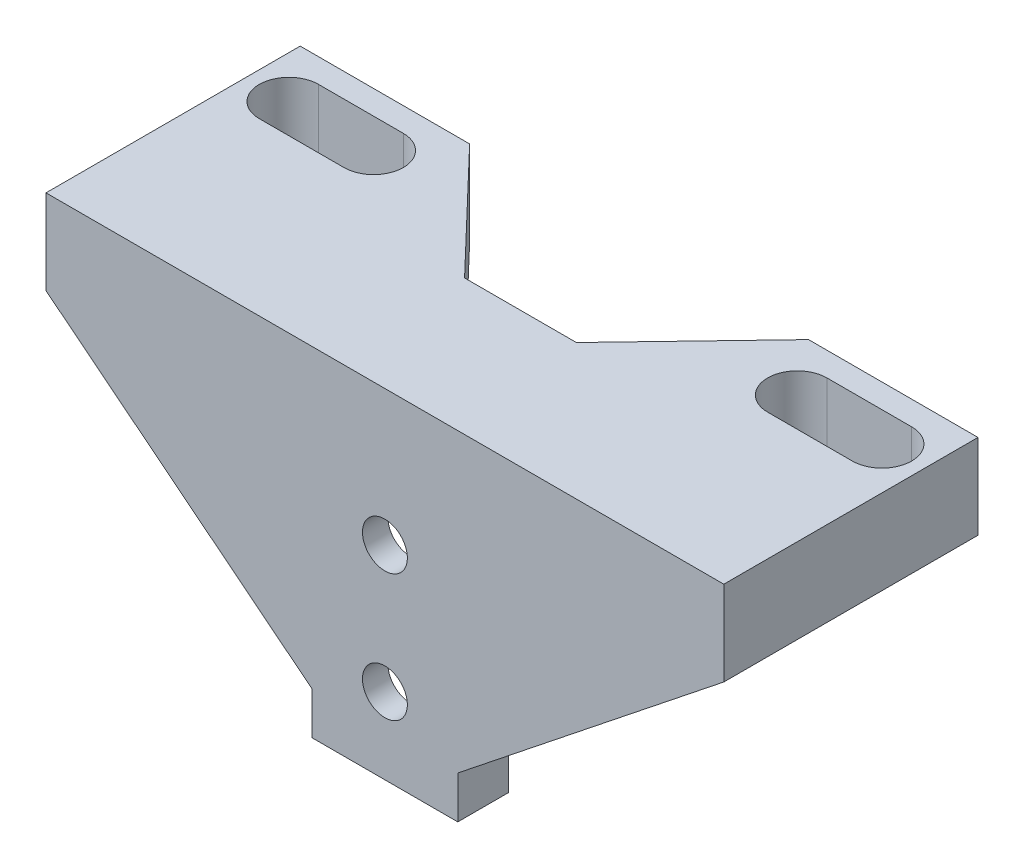
from build123d import *

# Parameters (mm, degrees)
ESQUISSE1_W             = 13.2
ESQUISSE1_H             = 30
ESQUISSE1_W_2           = 2
BOSS_EXTRU_1_DEPTH      = 3
ESQUISSE2_W             = 2
ESQUISSE2_H             = 30
BOSS_EXTRU_2_DEPTH      = 3
BOSS_EXTRU_3_DEPTH      = 10
BOSS_EXTRU_4_DEPTH      = 6
ESQUISSE6_R             = 2.65
ENL_V_MAT_EXTRU_1_DEPTH = 4
ENL_V_MAT_EXTRU_2_DEPTH = 41
CHANFREIN2_SIZE         = 10


with BuildPart() as part:
    # Esquisse1 → Boss.-Extru.1 (new body)
    with BuildSketch(Plane.XY):
        with Locations((-0.437888948, -2.316831683)):
            Rectangle(ESQUISSE1_W, ESQUISSE1_H)
        with Locations((-8.037888948, -2.316831683)):
            Rectangle(ESQUISSE1_W_2, ESQUISSE1_H)
        with Locations((7.162111052, -2.316831683)):
            Rectangle(ESQUISSE1_W_2, ESQUISSE1_H)
    extrude(amount=BOSS_EXTRU_1_DEPTH)

    # Esquisse2 → Boss.-Extru.2 (add)
    with BuildSketch(Plane(origin=(0, 0, 0), x_dir=(-1, 0, 0), z_dir=(0, 0, -1))):
        with Locations((-7.162111052, -2.316831683)):
            Rectangle(ESQUISSE2_W, ESQUISSE2_H)
        with Locations((8.037888948, -2.316831683)):
            Rectangle(ESQUISSE2_W, ESQUISSE2_H)
    extrude(amount=BOSS_EXTRU_2_DEPTH)

    # Esquisse3 → Boss.-Extru.3 (add)
    with BuildSketch(Plane(origin=(0, 12.683168317, 0), x_dir=(1, 0, 0), z_dir=(0, 1, 0))):
        Polygon((19.562111052, 27), (6.162111052, 13), (-7.037888948, 13), (-20.437888948, 27), (-40.437888948, 27), (-40.437888948, -3), (39.562111052, -3), (39.562111052, 27), align=None)
    extrude(amount=BOSS_EXTRU_3_DEPTH)

    # Esquisse5 → Boss.-Extru.4 (add)
    with BuildSketch(Plane.XY.offset(3)):
        Polygon((-9.037888948, 12.683168317), (-40.437888948, 12.683168317), (-9.037888948, -12.316831683), align=None)
        Polygon((8.162111052, -12.316831683), (39.562111052, 12.683168317), (8.162111052, 12.683168317), align=None)
    extrude(amount=-BOSS_EXTRU_4_DEPTH)

    # Esquisse6 → Enlèv. mat.-Extru.1 (cut, through all)
    with BuildSketch(Plane(origin=(0, 0, 0), x_dir=(-1, 0, 0), z_dir=(0, 0, -1))):
        with Locations((0.437888948, 6.683168317)):
            Circle(ESQUISSE6_R)
        with Locations((0.437888948, -8.316831683)):
            Circle(ESQUISSE6_R)
    extrude(amount=-ENL_V_MAT_EXTRU_1_DEPTH, mode=Mode.SUBTRACT)

    # Esquisse7 → Enlèv. mat.-Extru.2 (cut, through all)
    with BuildSketch(Plane(origin=(0, 22.683168317, 0), x_dir=(1, 0, 0), z_dir=(0, 1, 0))):
        with BuildLine():
            Line((-25.437888948, 17.169217815), (-35.437888948, 17.169217815))
            ThreePointArc((-35.437888948, 17.169217815), (-38.937888948, 20.669217815), (-35.437888948, 24.169217815))
            Line((-35.437888948, 24.169217815), (-25.437888948, 24.169217815))
            ThreePointArc((-25.437888948, 24.169217815), (-21.937888948, 20.669217815), (-25.437888948, 17.169217815))
        make_face()
        with BuildLine():
            Line((34.562111052, 17.169217815), (24.562111052, 17.169217815))
            ThreePointArc((24.562111052, 17.169217815), (21.062111052, 20.669217815), (24.562111052, 24.169217815))
            Line((24.562111052, 24.169217815), (34.562111052, 24.169217815))
            ThreePointArc((34.562111052, 24.169217815), (38.062111052, 20.669217815), (34.562111052, 17.169217815))
        make_face()
    extrude(amount=-ENL_V_MAT_EXTRU_2_DEPTH, mode=Mode.SUBTRACT)

    # Chanfrein2
    chanfrein2_edges = [part.edges().sort_by_distance(p)[0] for p in [
        (22.862111052, 12.683168317, -3),
        (-23.737888948, 12.683168317, -3),
    ]]
    chamfer(chanfrein2_edges, length=CHANFREIN2_SIZE)


solid = part.part
